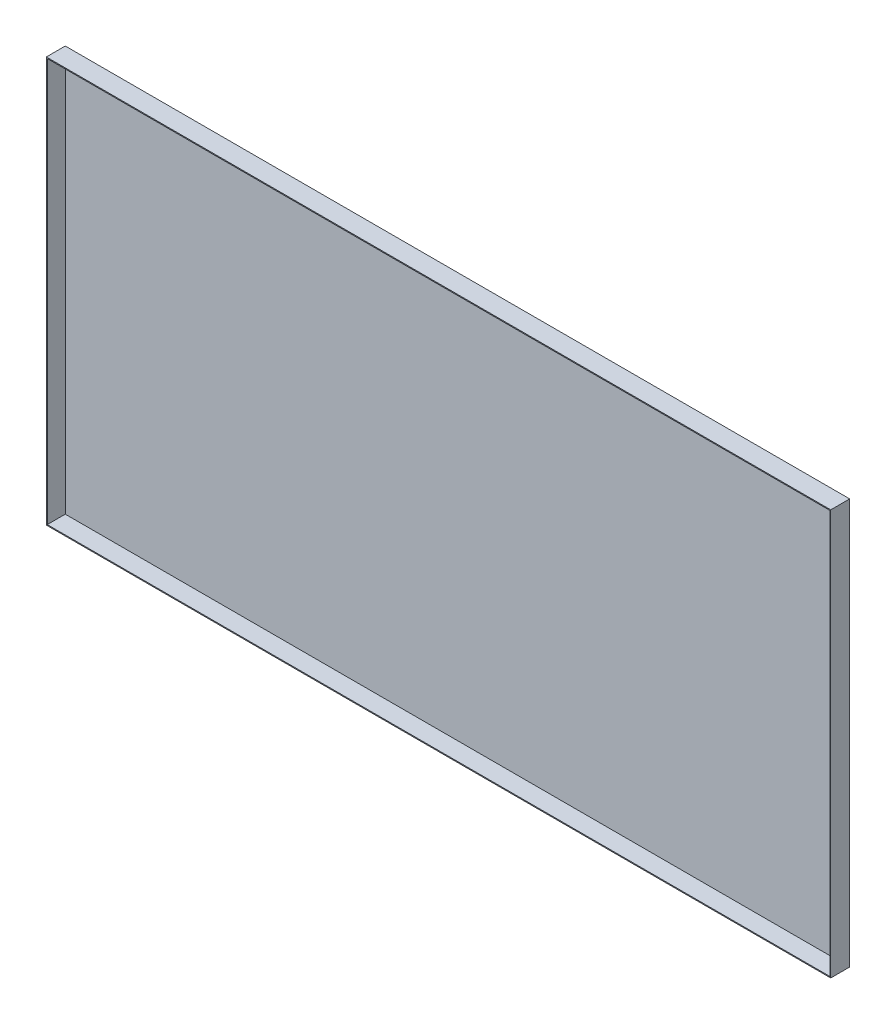
from build123d import *

# Parameters (mm, degrees)
SKETCH_1_W      = 828
SKETCH_1_H      = 428
EXTRUDE_1_DEPTH = 20
SHELL_1_T       = -1


with BuildPart() as part:
    # 草图1 → 凸台-拉伸1 (new body)
    with BuildSketch(Plane.XY):
        Rectangle(SKETCH_1_W, SKETCH_1_H)
    extrude(amount=EXTRUDE_1_DEPTH)

    # 抽壳1
    shell_1_openings = [part.faces().sort_by_distance(p)[0] for p in [
        (0, 0, 20),
    ]]
    offset(amount=SHELL_1_T, openings=shell_1_openings, kind=Kind.INTERSECTION)


solid = part.part
